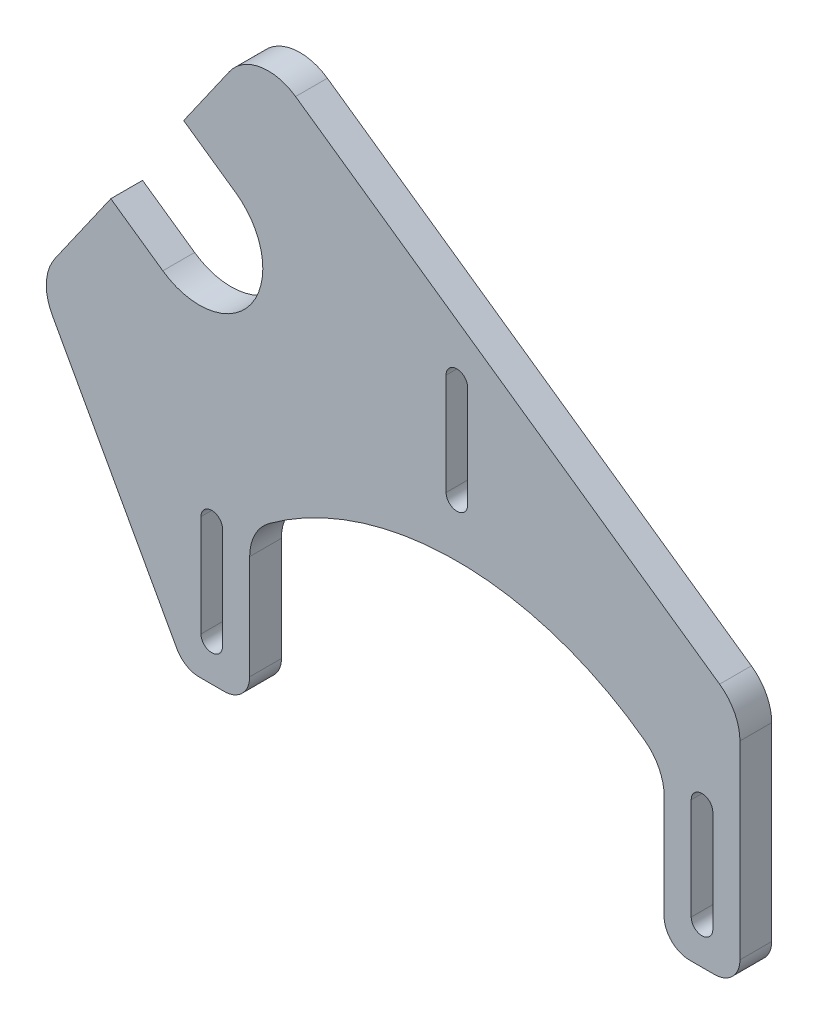
from build123d import *

# Parameters (mm, degrees)
EXTRUDE1_DEPTH     = 6.35
CUT_EXTRUDE3_REACH = 8.35
FILLET1_R          = 9.525


with BuildPart() as part:
    # Sketch1 → Extrude1 (new body)
    with BuildSketch(Plane.XY):
        with BuildLine():
            Line((-41.42, 12.7), (-41.42, -12.7))
            ThreePointArc((-41.42, -12.7), (-42.907897552, -16.292102448), (-46.5, -17.78))
            Line((-46.5, -17.78), (-51.5, -17.78))
            ThreePointArc((-51.5, -17.78), (-54.085377818, -17.072896242), (-55.951019269, -15.148433677))
            Line((-55.951019269, -15.148433677), (-83.74924785, 35.386098748))
            Line((-83.74924785, 35.386098748), (-69.180406366, 56.192560673))
            Line((-69.180406366, 56.192560673), (-58.777175404, 48.908139931))
            ThreePointArc((-58.777175404, 48.908139931), (-41.0895237, 52.026950152), (-44.208333921, 69.714601856))
            Line((-44.208333921, 69.714601856), (-54.611564883, 76.999022598))
            Line((-54.611564883, 76.999022598), (-40.0427234, 97.805484523))
            Line((-40.0427234, 97.805484523), (56.58, 30.149525236))
            Line((56.58, 30.149525236), (56.58, -12.7))
            ThreePointArc((56.58, -12.7), (55.092102448, -16.292102448), (51.5, -17.78))
            Line((51.5, -17.78), (46.5, -17.78))
            ThreePointArc((46.5, -17.78), (42.907897552, -16.292102448), (41.42, -12.7))
            Line((41.42, -12.7), (41.42, 12.7))
            ThreePointArc((41.42, 12.7), (0, 28.068579909), (-41.42, 12.7))
        make_face()
    extrude(amount=EXTRUDE1_DEPTH)

    # Sketch4 → Cut-Extrude3 (cut, up to next)
    with BuildSketch(Plane.XY.offset(6.35), mode=Mode.PRIVATE) as cut_extrude3_sk1:
        with BuildLine():
            Line((-51.159, -10.16), (-51.159, 10.16))
            ThreePointArc((-51.159, 10.16), (-49, 12.319), (-46.841, 10.16))
            Line((-46.841, 10.16), (-46.841, -10.16))
            ThreePointArc((-46.841, -10.16), (-49, -12.319), (-51.159, -10.16))
        make_face()
    cut_extrude3_tool1 = extrude(cut_extrude3_sk1.sketch, amount=-CUT_EXTRUDE3_REACH, mode=Mode.PRIVATE) & part.part
    add(cut_extrude3_tool1.solids().sort_by_distance((-49, 0, 6.35))[0], mode=Mode.SUBTRACT)
    # Sketch4 → Cut-Extrude3 (cut, up to next)
    with BuildSketch(Plane.XY.offset(6.35), mode=Mode.PRIVATE) as cut_extrude3_sk2:
        with BuildLine():
            Line((2.159, 38.84), (2.159, 59.16))
            ThreePointArc((2.159, 59.16), (0, 61.319), (-2.159, 59.16))
            Line((-2.159, 59.16), (-2.159, 38.84))
            ThreePointArc((-2.159, 38.84), (0, 36.681), (2.159, 38.84))
        make_face()
    cut_extrude3_tool2 = extrude(cut_extrude3_sk2.sketch, amount=-CUT_EXTRUDE3_REACH, mode=Mode.PRIVATE) & part.part
    add(cut_extrude3_tool2.solids().sort_by_distance((0, 49, 6.35))[0], mode=Mode.SUBTRACT)
    # Sketch4 → Cut-Extrude3 (cut, up to next)
    with BuildSketch(Plane.XY.offset(6.35), mode=Mode.PRIVATE) as cut_extrude3_sk3:
        with BuildLine():
            Line((51.159, -10.16), (51.159, 10.16))
            ThreePointArc((51.159, 10.16), (49, 12.319), (46.841, 10.16))
            Line((46.841, 10.16), (46.841, -10.16))
            ThreePointArc((46.841, -10.16), (49, -12.319), (51.159, -10.16))
        make_face()
    cut_extrude3_tool3 = extrude(cut_extrude3_sk3.sketch, amount=-CUT_EXTRUDE3_REACH, mode=Mode.PRIVATE) & part.part
    add(cut_extrude3_tool3.solids().sort_by_distance((49, 0, 6.35))[0], mode=Mode.SUBTRACT)

    # Fillet1
    fillet1_edges = [part.edges().sort_by_distance(p)[0] for p in [
        (-41.42, 12.7, 3.175),
        (-83.74924785, 35.386098748, 3.175),
        (-40.0427234, 97.805484523, 3.175),
        (56.58, 30.149525236, 3.175),
        (41.42, 12.7, 3.175),
    ]]
    fillet(fillet1_edges, radius=FILLET1_R)


solid = part.part
